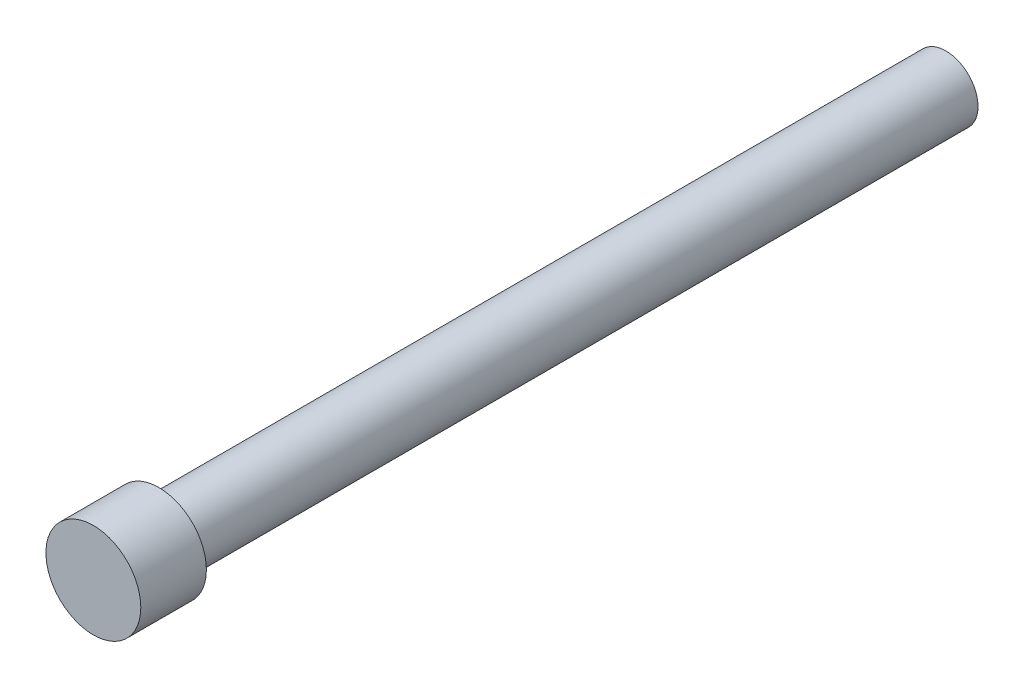
from build123d import *

# Parameters (mm, degrees)
CROQUIS1_R              = 2.45
SALIENTE_EXTRUIR1_DEPTH = 60
CROQUIS2_R              = 3.617598783
SALIENTE_EXTRUIR2_DEPTH = 5


with BuildPart() as part:
    # Croquis1 → Saliente-Extruir1 (new body)
    with BuildSketch(Plane.XY):
        with Locations((-17.273503229, 7.441808597)):
            Circle(CROQUIS1_R)
    extrude(amount=SALIENTE_EXTRUIR1_DEPTH)

    # Croquis2 → Saliente-Extruir2 (add)
    with BuildSketch(Plane.XY.offset(60)):
        with Locations((-17.273503229, 7.441808597)):
            Circle(CROQUIS2_R)
    extrude(amount=SALIENTE_EXTRUIR2_DEPTH)


solid = part.part
